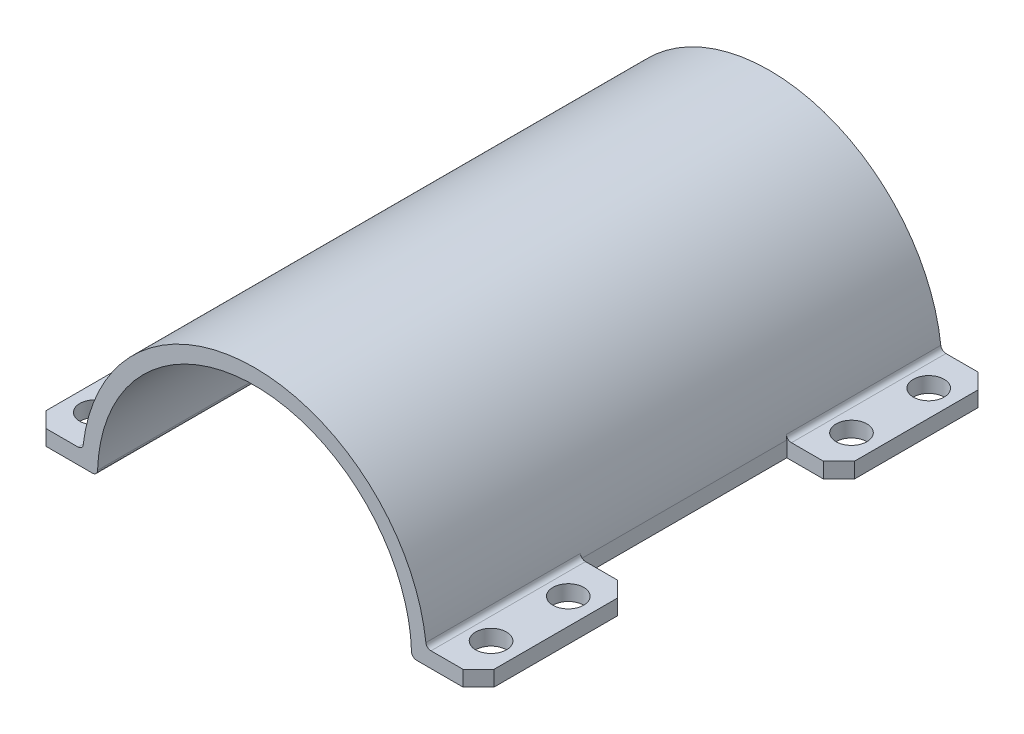
from build123d import *

# Parameters (mm, degrees)
BOSS_EXTRUDE1_DEPTH     = 100
SKETCH3_W               = 10.134598759
SKETCH3_H               = 40
CUT_EXTRUDE1_DEPTH      = 60
SKETCH4_R               = 3
CUT_EXTRUDE2_DEPTH      = 60
MIRROR4_COPY_1_SKETCH_R = 3
MIRROR4_COPY_1_DEPTH    = 60
CHAMFER1_SIZE           = 3
FILLET1_R               = 1


with BuildPart() as part:
    # Sketch1 → Boss-Extrude1 (new body)
    with BuildSketch(Plane.XY):
        with BuildLine():
            Line((-43.5, 0), (-33.5, 0))
            ThreePointArc((-33.5, 0), (-33.466333393, 1.501508976), (-33.365401241, 3))
            Line((-33.365401241, 3), (-43.5, 3))
            Line((-43.5, 3), (-43.5, 0))
        make_face()
        with BuildLine():
            Line((-33.5, 0), (-30.5, 0))
            ThreePointArc((-30.5, 0), (0, 30.5), (30.5, 0))
            Line((30.5, 0), (33.5, 0))
            ThreePointArc((33.5, 0), (33.466333393, 1.501508976), (33.365401241, 3))
            ThreePointArc((33.365401241, 3), (0, 33.5), (-33.365401241, 3))
            ThreePointArc((-33.365401241, 3), (-33.466333393, 1.501508976), (-33.5, 0))
        make_face()
        with BuildLine():
            ThreePointArc((33.365401241, 3), (33.466333393, 1.501508976), (33.5, 0))
            Line((33.5, 0), (43.5, 0))
            Line((43.5, 0), (43.5, 3))
            Line((43.5, 3), (33.365401241, 3))
        make_face()
    extrude(amount=BOSS_EXTRUDE1_DEPTH)

    # Sketch3 → Cut-Extrude1 (cut)
    with BuildSketch(Plane(origin=(0, 3, 0), x_dir=(1, 0, 0), z_dir=(0, 1, 0))):
        with Locations((38.432700621, -50)):
            Rectangle(SKETCH3_W, SKETCH3_H)
        with Locations((-38.432700621, -50)):
            Rectangle(SKETCH3_W, SKETCH3_H)
    extrude(amount=-CUT_EXTRUDE1_DEPTH, mode=Mode.SUBTRACT)

    # Sketch4 → Cut-Extrude2 (cut)
    with BuildSketch(Plane(origin=(0, 3, 0), x_dir=(1, 0, 0), z_dir=(0, 1, 0))):
        with Locations((38.432700621, -22.5)):
            Circle(SKETCH4_R)
        with Locations((38.432700621, -7.5)):
            Circle(SKETCH4_R)
    cut_extrude2 = extrude(amount=-CUT_EXTRUDE2_DEPTH, mode=Mode.SUBTRACT)

    # Mirror3: Cut-Extrude2 across plane
    add(cut_extrude2.mirror(Plane(origin=(0, 0, 50), x_dir=(1, 0, 0), z_dir=(0, 0, -1))), mode=Mode.SUBTRACT)

    # Mirror4: Cut-Extrude2 across plane
    add(cut_extrude2.mirror(Plane(origin=(0, 0, 0), x_dir=(0, 0, 1), z_dir=(1, 0, 0))), mode=Mode.SUBTRACT)

    # Mirror4 copy 1 sketch → Mirror4 copy 1 (cut)
    with BuildSketch(Plane(origin=(0, 3, 100), x_dir=(-1, 0, 0), z_dir=(0, 1, 0))):
        with Locations((38.432700621, -22.5)):
            Circle(MIRROR4_COPY_1_SKETCH_R)
        with Locations((38.432700621, -7.5)):
            Circle(MIRROR4_COPY_1_SKETCH_R)
    extrude(amount=-MIRROR4_COPY_1_DEPTH, mode=Mode.SUBTRACT)

    # Chamfer1
    chamfer1_edges = [part.edges().sort_by_distance(p)[0] for p in [
        (-43.5, 1.5, 0),
        (43.5, 1.5, 0),
        (43.5, 1.5, 100),
        (-43.5, 1.5, 70),
        (-43.5, 1.5, 30),
        (43.5, 1.5, 30),
        (43.5, 1.5, 70),
        (-43.5, 1.5, 100),
    ]]
    chamfer(chamfer1_edges, length=CHAMFER1_SIZE)

    # Fillet1
    fillet1_edges = [part.edges().sort_by_distance(p)[0] for p in [
        (-33.365401241, 3, 85),
        (33.365401241, 3, 85),
        (30.5, 0, 50),
        (-30.5, 0, 50),
        (-33.365401241, 3, 15),
        (33.365401241, 3, 15),
    ]]
    fillet(fillet1_edges, radius=FILLET1_R)


solid = part.part
